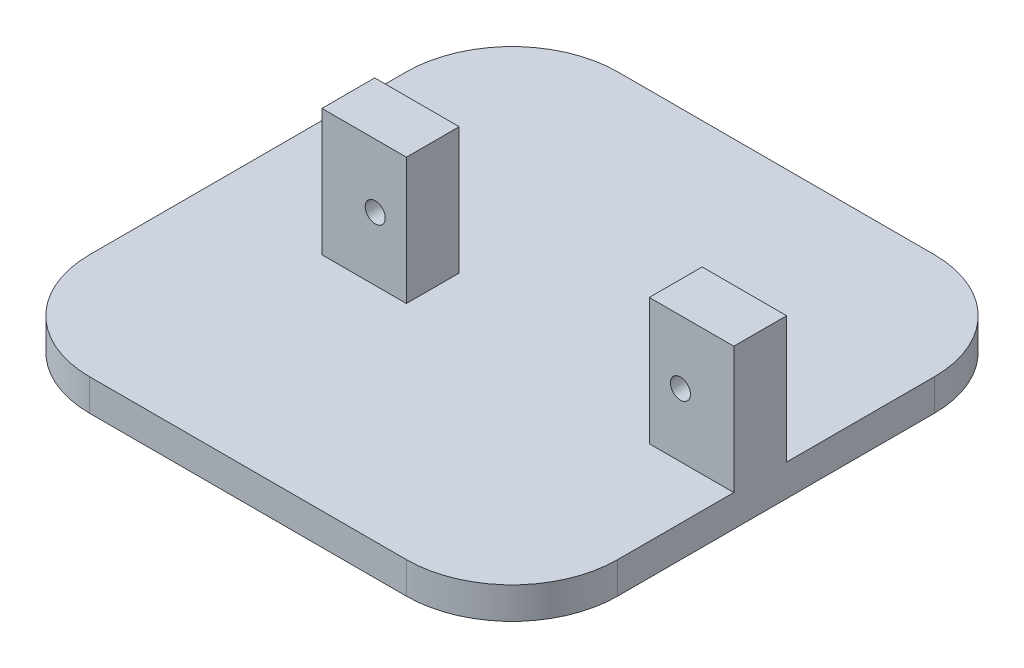
from build123d import *

# Parameters (mm, degrees)
EXTRUDE_1_DEPTH     = 3
SKETCH_2_W          = 8
SKETCH_2_H          = 5
EXTRUDE_2_DEPTH     = 15
SKETCH_3_R          = 0.95
CUT_EXTRUDE_1_DEPTH = 15


with BuildPart() as part:
    # 草图1 → 凸台-拉伸1 (new body)
    with BuildSketch(Plane(origin=(0, 0, 0), x_dir=(1, 0, 0), z_dir=(0, 1, 0))):
        with BuildLine():
            Line((-15, 25), (15, 25))
            ThreePointArc((15, 25), (22.071067812, 22.071067812), (25, 15))
            Line((25, 15), (25, -15))
            ThreePointArc((25, -15), (22.071067812, -22.071067812), (15, -25))
            Line((15, -25), (-15, -25))
            ThreePointArc((-15, -25), (-22.071067812, -22.071067812), (-25, -15))
            Line((-25, -15), (-25, 15))
            ThreePointArc((-25, 15), (-22.071067812, 22.071067812), (-15, 25))
        make_face()
    extrude(amount=EXTRUDE_1_DEPTH)

    # 草图2 → 凸台-拉伸2 (add)
    with BuildSketch(Plane(origin=(0, 0, 0), x_dir=(1, 0, 0), z_dir=(0, 1, 0))):
        with Locations((21, -1.5)):
            Rectangle(SKETCH_2_W, SKETCH_2_H)
        with Locations((-10, -1.5)):
            Rectangle(SKETCH_2_W, SKETCH_2_H)
    extrude(amount=EXTRUDE_2_DEPTH)

    # 草图3 → 切除-拉伸1 (cut)
    with BuildSketch(Plane(origin=(0, 0, -1), x_dir=(-1, 0, 0), z_dir=(0, 0, -1))):
        with Locations((8.95, 9)):
            Circle(SKETCH_3_R)
        with Locations((-19.95, 9)):
            Circle(SKETCH_3_R)
    extrude(amount=-CUT_EXTRUDE_1_DEPTH, mode=Mode.SUBTRACT)


solid = part.part
